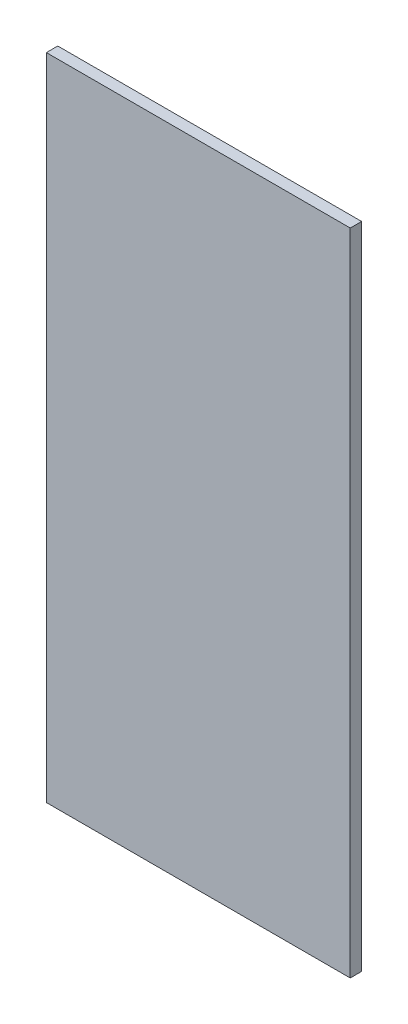
from build123d import *

# Parameters (mm, degrees)
ESBO_O1_W                = 80
ESBO_O1_H                = 171
RESSALTO_EXTRUS_O1_DEPTH = 3


with BuildPart() as part:
    # Esboço1 → Ressalto-extrusão1 (new body)
    with BuildSketch(Plane.XY):
        with Locations((6.627906977, -58.755813953)):
            Rectangle(ESBO_O1_W, ESBO_O1_H)
    extrude(amount=RESSALTO_EXTRUS_O1_DEPTH)


solid = part.part
